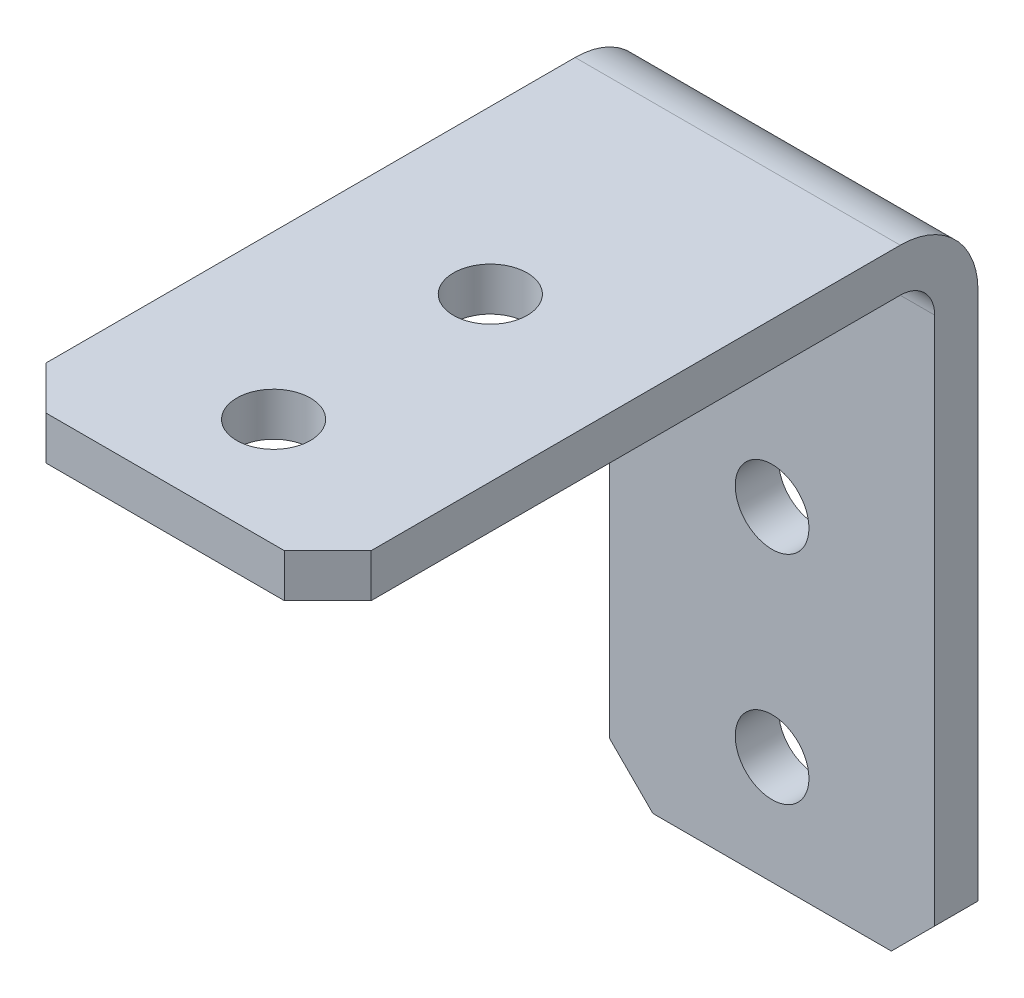
from build123d import *

# Parameters (mm, degrees)
SKETCH1_W                      = 30
SKETCH1_H                      = 30
BOSS_EXTRUDE1_DEPTH            = 15
SKETCH2_W                      = 28
SKETCH2_H                      = 28
CUT_EXTRUDE1_DEPTH             = 16
F_3_4_3_4_DIAMETER_HOLE1_D     = 3.4
F_3_4_3_4_DIAMETER_HOLE1_DEPTH = 2
F_3_4_3_4_DIAMETER_HOLE2_D     = 3.4
F_3_4_3_4_DIAMETER_HOLE2_DEPTH = 2
CHAMFER1_SIZE                  = 2
FILLET1_R                      = 1.5875
FILLET2_R                      = 3.5875


with BuildPart() as part:
    # Sketch1 → Boss-Extrude1 (new body)
    with BuildSketch(Plane(origin=(-7.5, 0, 0), x_dir=(0, -1, 0), z_dir=(-1, 0, 0))):
        with Locations((0, 13)):
            Rectangle(SKETCH1_W, SKETCH1_H)
    extrude(amount=-BOSS_EXTRUDE1_DEPTH)

    # Sketch2 → Cut-Extrude1 (cut, through all)
    with BuildSketch(Plane(origin=(7.5, 0, 0), x_dir=(0, 0, -1), z_dir=(1, 0, 0))):
        with Locations((-14, -1)):
            Rectangle(SKETCH2_W, SKETCH2_H)
    extrude(amount=-CUT_EXTRUDE1_DEPTH, mode=Mode.SUBTRACT)

    # Ø3.4 (3.4) Diameter Hole1
    with Locations(Plane.XY):
        with Locations((0, 0), (0, -10)):
            Hole(F_3_4_3_4_DIAMETER_HOLE1_D / 2, depth=F_3_4_3_4_DIAMETER_HOLE1_DEPTH)

    # Ø3.4 (3.4) Diameter Hole2
    with Locations(Plane(origin=(0, 13, 0), x_dir=(-1, 0, 0), z_dir=(0, -1, 0))):
        with Locations((0, -13), (0, -23)):
            Hole(F_3_4_3_4_DIAMETER_HOLE2_D / 2, depth=F_3_4_3_4_DIAMETER_HOLE2_DEPTH)

    # Chamfer1
    chamfer1_edges = [part.edges().sort_by_distance(p)[0] for p in [
        (-7.5, 14, 28),
        (7.5, 14, 28),
        (-7.5, -15, -1),
        (7.5, -15, -1),
    ]]
    chamfer(chamfer1_edges, length=CHAMFER1_SIZE)

    # Fillet1
    fillet1_edges = [part.edges().sort_by_distance(p)[0] for p in [
        (0, 13, 0),
    ]]
    fillet(fillet1_edges, radius=FILLET1_R)

    # Fillet2
    fillet2_edges = [part.edges().sort_by_distance(p)[0] for p in [
        (0, 15, -2),
    ]]
    fillet(fillet2_edges, radius=FILLET2_R)


solid = part.part
